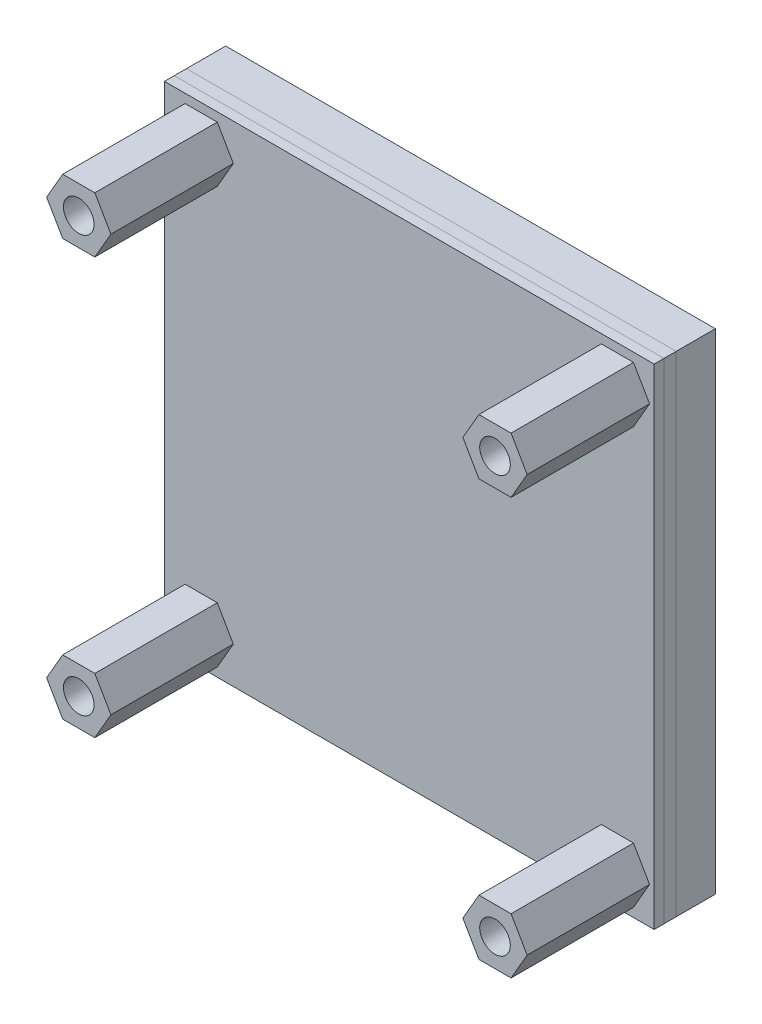
from build123d import *

# Parameters (mm, degrees)
SKETCH1_W             = 40
SKETCH1_H             = 40
BOSS_EXTRUDE1_DEPTH   = 3.2
SKETCH2_W             = 40
SKETCH2_H             = 40
BOSS_EXTRUDE2_DEPTH   = 1
SKETCH3_W             = 40
SKETCH3_H             = 40
BOSS_EXTRUDE3_DEPTH   = 0.8
SKETCH4_R             = 1.25
BOSS_EXTRUDE4_DEPTH   = 10
BOSS_EXTRUDE4_2_DEPTH = 10
BOSS_EXTRUDE4_3_DEPTH = 10
BOSS_EXTRUDE4_4_DEPTH = 10


with BuildPart() as part:
    # Sketch1 → Boss-Extrude1 (new body)
    with BuildSketch(Plane.XY):
        with Locations((3.473053892, 0.718562874)):
            Rectangle(SKETCH1_W, SKETCH1_H)
    extrude(amount=BOSS_EXTRUDE1_DEPTH)


with BuildPart() as body_2:
    # Sketch2 → Boss-Extrude2 (new body)
    with BuildSketch(Plane.XY.offset(3.2)):
        with Locations((3.473053892, 0.718562874)):
            Rectangle(SKETCH2_W, SKETCH2_H)
    extrude(amount=BOSS_EXTRUDE2_DEPTH)


with BuildPart() as body_3:
    # Sketch3 → Boss-Extrude3 (new body)
    with BuildSketch(Plane.XY.offset(4.2)):
        with Locations((3.473053892, 0.718562874)):
            Rectangle(SKETCH3_W, SKETCH3_H)
    extrude(amount=BOSS_EXTRUDE3_DEPTH)


with BuildPart() as body_4:
    # Sketch4 → Boss-Extrude4 (new body)
    with BuildSketch(Plane.XY.offset(5)):
        Polygon((-10.901946108, 17.718562874), (-12.214446108, 19.991879559), (-14.839446108, 19.991879559), (-16.151946108, 17.718562874), (-14.839446108, 15.445246189), (-12.214446108, 15.445246189), align=None)
        with Locations((-13.526946108, 17.718562874)):
            Circle(SKETCH4_R, mode=Mode.SUBTRACT)
    extrude(amount=BOSS_EXTRUDE4_DEPTH)


with BuildPart() as body_5:
    # Sketch4 → Boss-Extrude4 2 (new body)
    with BuildSketch(Plane.XY.offset(5)):
        Polygon((17.848053892, 17.718562874), (19.160553892, 15.445246189), (21.785553892, 15.445246189), (23.098053892, 17.718562874), (21.785553892, 19.991879559), (19.160553892, 19.991879559), align=None)
        with Locations((20.473053892, 17.718562874)):
            Circle(SKETCH4_R, mode=Mode.SUBTRACT)
    extrude(amount=BOSS_EXTRUDE4_2_DEPTH)


with BuildPart() as body_6:
    # Sketch4 → Boss-Extrude4 3 (new body)
    with BuildSketch(Plane.XY.offset(5)):
        Polygon((-10.901946108, -16.281437126), (-12.214446108, -14.008120441), (-14.839446108, -14.008120441), (-16.151946108, -16.281437126), (-14.839446108, -18.554753811), (-12.214446108, -18.554753811), align=None)
        with Locations((-13.526946108, -16.281437126)):
            Circle(SKETCH4_R, mode=Mode.SUBTRACT)
    extrude(amount=BOSS_EXTRUDE4_3_DEPTH)


with BuildPart() as body_7:
    # Sketch4 → Boss-Extrude4 4 (new body)
    with BuildSketch(Plane.XY.offset(5)):
        Polygon((23.098053892, -16.281437126), (21.785553892, -14.008120441), (19.160553892, -14.008120441), (17.848053892, -16.281437126), (19.160553892, -18.554753811), (21.785553892, -18.554753811), align=None)
        with Locations((20.473053892, -16.281437126)):
            Circle(SKETCH4_R, mode=Mode.SUBTRACT)
    extrude(amount=BOSS_EXTRUDE4_4_DEPTH)


solid = Compound([part.part, body_2.part, body_3.part, body_4.part, body_5.part, body_6.part, body_7.part])
